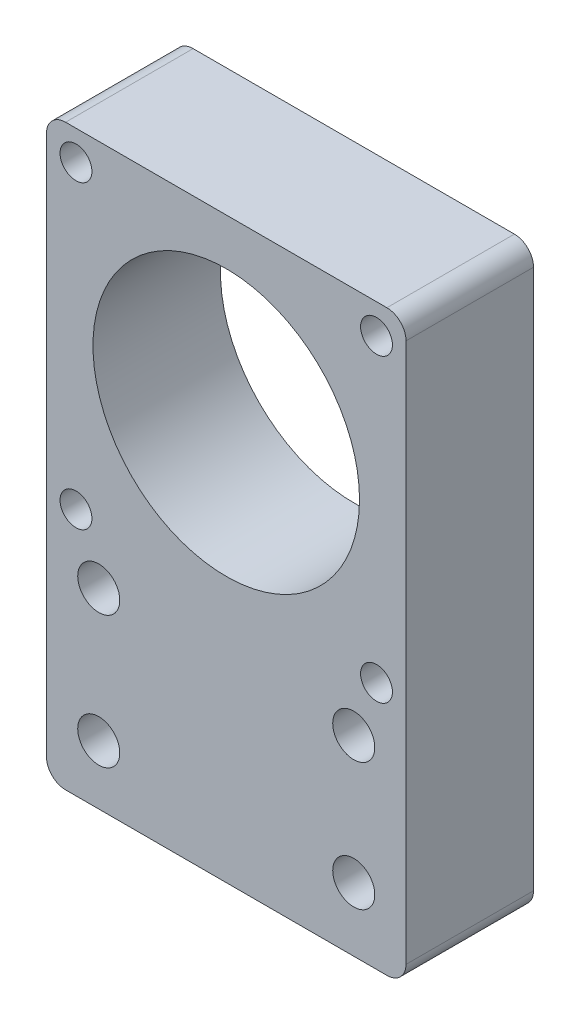
from build123d import *

# Parameters (mm, degrees)
SKETCH1_W               = 56.4
SKETCH1_H               = 56.4
BOSS_EXTRUDE1_DEPTH     = 20
SKETCH2_R               = 20.904355549
CUT_EXTRUDE2_DEPTH      = 20
SKETCH3_W               = 56.4
SKETCH3_H               = 34.3
BOSS_EXTRUDE2_DEPTH     = 20
FILLET1_R               = 3
TAP_DRILL_FOR_M6_TAP1_D = 5
M6_CLEARANCE_HOLE1_D    = 6.6


with BuildPart() as part:
    # Sketch1 → Boss-Extrude1 (new body)
    with BuildSketch(Plane.XY):
        with Locations((0, 25)):
            Rectangle(SKETCH1_W, SKETCH1_H)
    extrude(amount=BOSS_EXTRUDE1_DEPTH)

    # Sketch2 → Cut-Extrude2 (cut)
    with BuildSketch(Plane.XY.offset(20)):
        with Locations((0, 25)):
            Circle(SKETCH2_R)
    extrude(amount=-CUT_EXTRUDE2_DEPTH, mode=Mode.SUBTRACT)

    # Sketch3 → Boss-Extrude2 (add)
    with BuildSketch(Plane(origin=(0, 0, 0), x_dir=(-1, 0, 0), z_dir=(0, 0, -1))):
        with Locations((0, -20.35)):
            Rectangle(SKETCH3_W, SKETCH3_H)
    extrude(amount=-BOSS_EXTRUDE2_DEPTH)

    # Fillet1
    fillet1_edges = [part.edges().sort_by_distance(p)[0] for p in [
        (28.2, -37.5, 10),
        (-28.2, -37.5, 10),
        (28.2, 53.2, 10),
        (-28.2, 53.2, 10),
    ]]
    fillet(fillet1_edges, radius=FILLET1_R)

    # Tap Drill for M6 Tap1 (through all)
    with Locations(Plane(origin=(0, 0, 0), x_dir=(-1, 0, 0), z_dir=(0, 0, -1))):
        with Locations((-23.57, 48.57), (23.57, 48.57), (-23.57, 1.43), (23.57, 1.43)):
            Hole(TAP_DRILL_FOR_M6_TAP1_D / 2)

    # M6 Clearance Hole1 (through all)
    with Locations(Plane(origin=(0, 0, 0), x_dir=(-1, 0, 0), z_dir=(0, 0, -1))):
        with Locations((-20, -7.5), (-20, -27.5), (20, -28.237657735), (20, -7.5)):
            Hole(M6_CLEARANCE_HOLE1_D / 2)


solid = part.part
